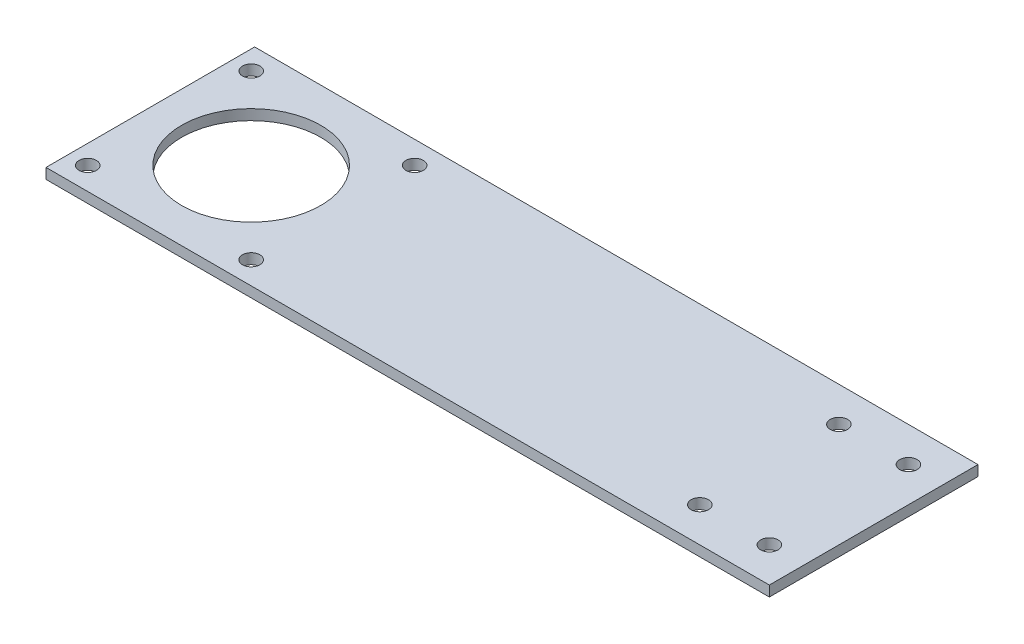
from build123d import *

# Parameters (mm, degrees)
SKETCH1_W           = 208
SKETCH1_H           = 60
SKETCH1_R           = 2.5
SKETCH1_R_2         = 20
BOSS_EXTRUDE1_DEPTH = 3


with BuildPart() as part:
    # Sketch1 → Boss-Extrude1 (new body)
    with BuildSketch(Plane(origin=(0, 0, 0), x_dir=(1, 0, 0), z_dir=(0, 1, 0))):
        with Locations((104, -30)):
            Rectangle(SKETCH1_W, SKETCH1_H)
        with Locations((5.5, -6.5)):
            Circle(SKETCH1_R, mode=Mode.SUBTRACT)
        with Locations((52.5, -6.5)):
            Circle(SKETCH1_R, mode=Mode.SUBTRACT)
        with Locations((52.5, -53.5)):
            Circle(SKETCH1_R, mode=Mode.SUBTRACT)
        with Locations((5.5, -53.5)):
            Circle(SKETCH1_R, mode=Mode.SUBTRACT)
        with Locations((29, -30)):
            Circle(SKETCH1_R_2, mode=Mode.SUBTRACT)
        with Locations((178, -50)):
            Circle(SKETCH1_R, mode=Mode.SUBTRACT)
        with Locations((198, -50)):
            Circle(SKETCH1_R, mode=Mode.SUBTRACT)
        with Locations((178, -10)):
            Circle(SKETCH1_R, mode=Mode.SUBTRACT)
        with Locations((198, -10)):
            Circle(SKETCH1_R, mode=Mode.SUBTRACT)
    extrude(amount=BOSS_EXTRUDE1_DEPTH)


solid = part.part
